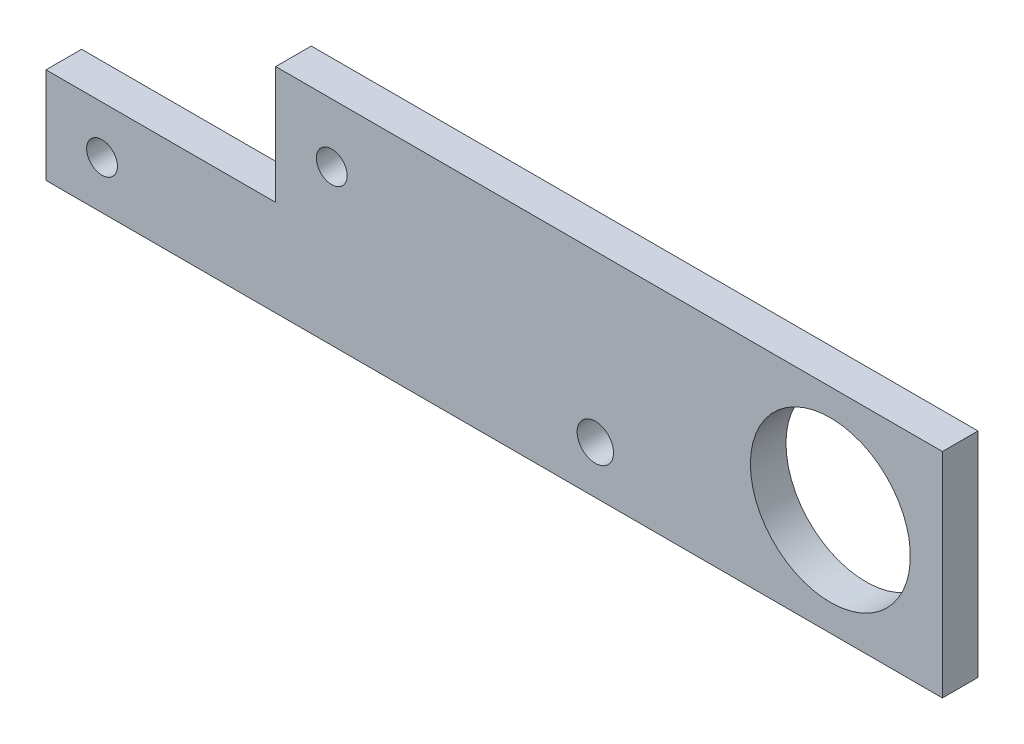
from build123d import *

# Parameters (mm, degrees)
SKETCH1_W           = 160
SKETCH1_H           = 38.1
BOSS_EXTRUDE1_DEPTH = 6.35
SKETCH2_R           = 14.275
CUT_EXTRUDE1_DEPTH  = 7.35
SKETCH3_W           = 41
SKETCH3_H           = 21
CUT_EXTRUDE2_DEPTH  = 7.35
SKETCH4_R           = 2.75
SKETCH4_R_2         = 3.25
CUT_EXTRUDE3_DEPTH  = 7.35


with BuildPart() as part:
    # Sketch1 → Boss-Extrude1 (new body)
    with BuildSketch(Plane.XY):
        with Locations((80, -19.05)):
            Rectangle(SKETCH1_W, SKETCH1_H)
    extrude(amount=BOSS_EXTRUDE1_DEPTH)

    # Sketch2 → Cut-Extrude1 (cut, through all)
    with BuildSketch(Plane(origin=(0, 0, 0), x_dir=(-1, 0, 0), z_dir=(0, 0, -1))):
        with Locations((-140, -19.05)):
            Circle(SKETCH2_R)
    extrude(amount=-CUT_EXTRUDE1_DEPTH, mode=Mode.SUBTRACT)

    # Sketch3 → Cut-Extrude2 (cut, through all)
    with BuildSketch(Plane.XY.offset(6.35)):
        with Locations((20.5, -10.5)):
            Rectangle(SKETCH3_W, SKETCH3_H)
    extrude(amount=-CUT_EXTRUDE2_DEPTH, mode=Mode.SUBTRACT)

    # Sketch4 → Cut-Extrude3 (cut, through all)
    with BuildSketch(Plane.XY.offset(6.35)):
        with Locations((10, -29.55)):
            Circle(SKETCH4_R)
        with Locations((51, -10.5)):
            Circle(SKETCH4_R)
        with Locations((98.049601269, -29.55)):
            Circle(SKETCH4_R_2)
    extrude(amount=-CUT_EXTRUDE3_DEPTH, mode=Mode.SUBTRACT)


solid = part.part
